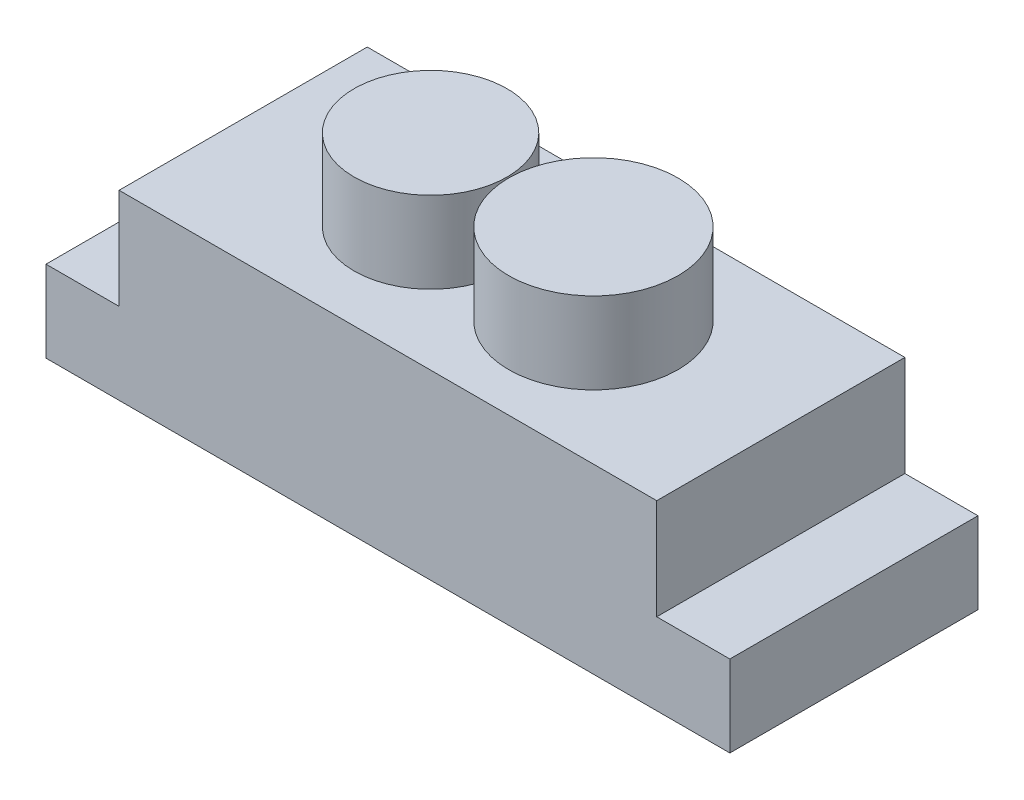
from build123d import *

# Parameters (mm, degrees)
SKETCH1_W           = 33.02
SKETCH1_H           = 15.24
BOSS_EXTRUDE1_DEPTH = 11.176
SKETCH2_R           = 4.7
SKETCH2_R_2         = 5.2
BOSS_EXTRUDE2_DEPTH = 5
SKETCH3_W           = 42
SKETCH3_H           = 15.24
BOSS_EXTRUDE3_DEPTH = 5


with BuildPart() as part:
    # Sketch1 → Boss-Extrude1 (new body)
    with BuildSketch(Plane(origin=(0, 0, 0), x_dir=(1, 0, 0), z_dir=(0, 1, 0))):
        Rectangle(SKETCH1_W, SKETCH1_H)
    extrude(amount=BOSS_EXTRUDE1_DEPTH)

    # Sketch2 → Boss-Extrude2 (add)
    with BuildSketch(Plane(origin=(0, 11.176, 0), x_dir=(1, 0, 0), z_dir=(0, 1, 0))):
        with Locations((-5, 0)):
            Circle(SKETCH2_R)
        with Locations((5, 0)):
            Circle(SKETCH2_R_2)
    extrude(amount=BOSS_EXTRUDE2_DEPTH)

    # Sketch3 → Boss-Extrude3 (add)
    with BuildSketch(Plane.XZ):
        Rectangle(SKETCH3_W, SKETCH3_H)
    extrude(amount=-BOSS_EXTRUDE3_DEPTH)


solid = part.part
